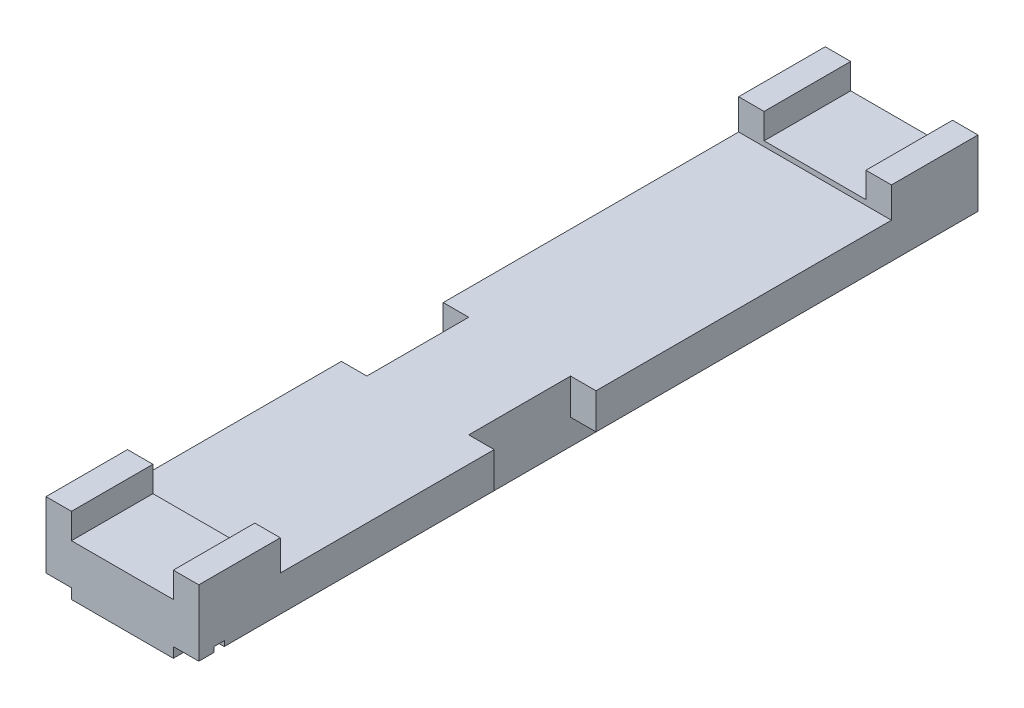
from build123d import *

# Parameters (mm, degrees)
SKETCH2_W           = 3
SKETCH2_H           = 15.3
BOSS_EXTRUDE1_DEPTH = 1.8
SKETCH3_W           = 12
SKETCH3_H           = 0.6
CUT_EXTRUDE1_DEPTH  = 4
SKETCH4_W           = 2.3
SKETCH4_H           = 0.3
SKETCH4_W_2         = 3
CUT_EXTRUDE2_DEPTH  = 4
SKETCH5_W           = 0.5
SKETCH5_H           = 2
CUT_EXTRUDE3_DEPTH  = 2.2
SKETCH8_W           = 2
SKETCH8_H           = 0.5
CUT_EXTRUDE5_DEPTH  = 16.3
SKETCH9_W           = 0.5
SKETCH9_H           = 0.5
CUT_EXTRUDE6_DEPTH  = 16.3
SKETCH10_W          = 0.2
SKETCH10_H          = 0.3
CUT_EXTRUDE7_DEPTH  = 4


with BuildPart() as part:
    # Sketch2 → Boss-Extrude1 (new body)
    with BuildSketch(Plane(origin=(0, 0, 0), x_dir=(1, 0, 0), z_dir=(0, 1, 0))):
        with Locations((0, 7.65)):
            Rectangle(SKETCH2_W, SKETCH2_H)
    extrude(amount=BOSS_EXTRUDE1_DEPTH)

    # Sketch3 → Cut-Extrude1 (cut, through all)
    with BuildSketch(Plane(origin=(1.5, 0, 0), x_dir=(0, 0, -1), z_dir=(1, 0, 0))):
        with Locations((7.6, 1.5)):
            Rectangle(SKETCH3_W, SKETCH3_H)
    extrude(amount=-CUT_EXTRUDE1_DEPTH, mode=Mode.SUBTRACT)

    # Sketch4 → Cut-Extrude2 (cut, through all)
    with BuildSketch(Plane(origin=(1.5, 0, 0), x_dir=(0, 0, -1), z_dir=(1, 0, 0))):
        with Locations((1.15, 0.15)):
            Rectangle(SKETCH4_W, SKETCH4_H)
        with Locations((13.8, 0.15)):
            Rectangle(SKETCH4_W_2, SKETCH4_H)
    extrude(amount=-CUT_EXTRUDE2_DEPTH, mode=Mode.SUBTRACT)

    # Sketch5 → Cut-Extrude3 (cut, through all)
    with BuildSketch(Plane(origin=(0, 1.2, 0), x_dir=(1, 0, 0), z_dir=(0, 1, 0))):
        with Locations((-1.25, 6.8)):
            Rectangle(SKETCH5_W, SKETCH5_H)
        with Locations((1.25, 6.8)):
            Rectangle(SKETCH5_W, SKETCH5_H)
    extrude(amount=-CUT_EXTRUDE3_DEPTH, mode=Mode.SUBTRACT)

    # Sketch8 → Cut-Extrude5 (cut, through all)
    with BuildSketch(Plane.XY):
        with Locations((0, 1.55)):
            Rectangle(SKETCH8_W, SKETCH8_H)
    extrude(amount=-CUT_EXTRUDE5_DEPTH, mode=Mode.SUBTRACT)

    # Sketch9 → Cut-Extrude6 (cut, through all)
    with BuildSketch(Plane.XY):
        with Locations((-1.25, 0.25)):
            Rectangle(SKETCH9_W, SKETCH9_H)
        with Locations((1.25, 0.25)):
            Rectangle(SKETCH9_W, SKETCH9_H)
    extrude(amount=-CUT_EXTRUDE6_DEPTH, mode=Mode.SUBTRACT)

    # Sketch10 → Cut-Extrude7 (cut, through all)
    with BuildSketch(Plane(origin=(1.5, 0, 0), x_dir=(0, 0, -1), z_dir=(1, 0, 0))):
        with Locations((0.4, 0.45)):
            Rectangle(SKETCH10_W, SKETCH10_H)
    extrude(amount=-CUT_EXTRUDE7_DEPTH, mode=Mode.SUBTRACT)


solid = part.part
